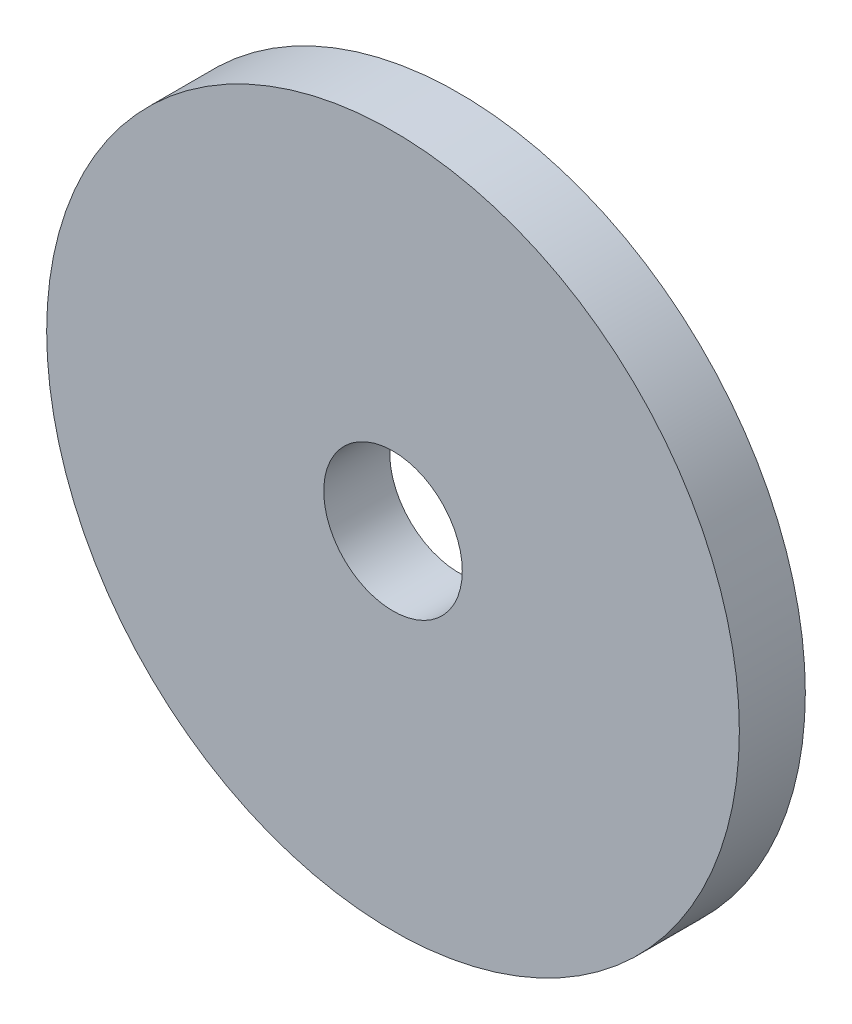
from build123d import *

# Parameters (mm, degrees)
SKETCH1_R           = 10.5
SKETCH1_R_2         = 2.1
BOSS_EXTRUDE1_DEPTH = 2


with BuildPart() as part:
    # Sketch1 → Boss-Extrude1 (new body)
    with BuildSketch(Plane.XY):
        Circle(SKETCH1_R)
        Circle(SKETCH1_R_2, mode=Mode.SUBTRACT)
    extrude(amount=BOSS_EXTRUDE1_DEPTH)


solid = part.part
